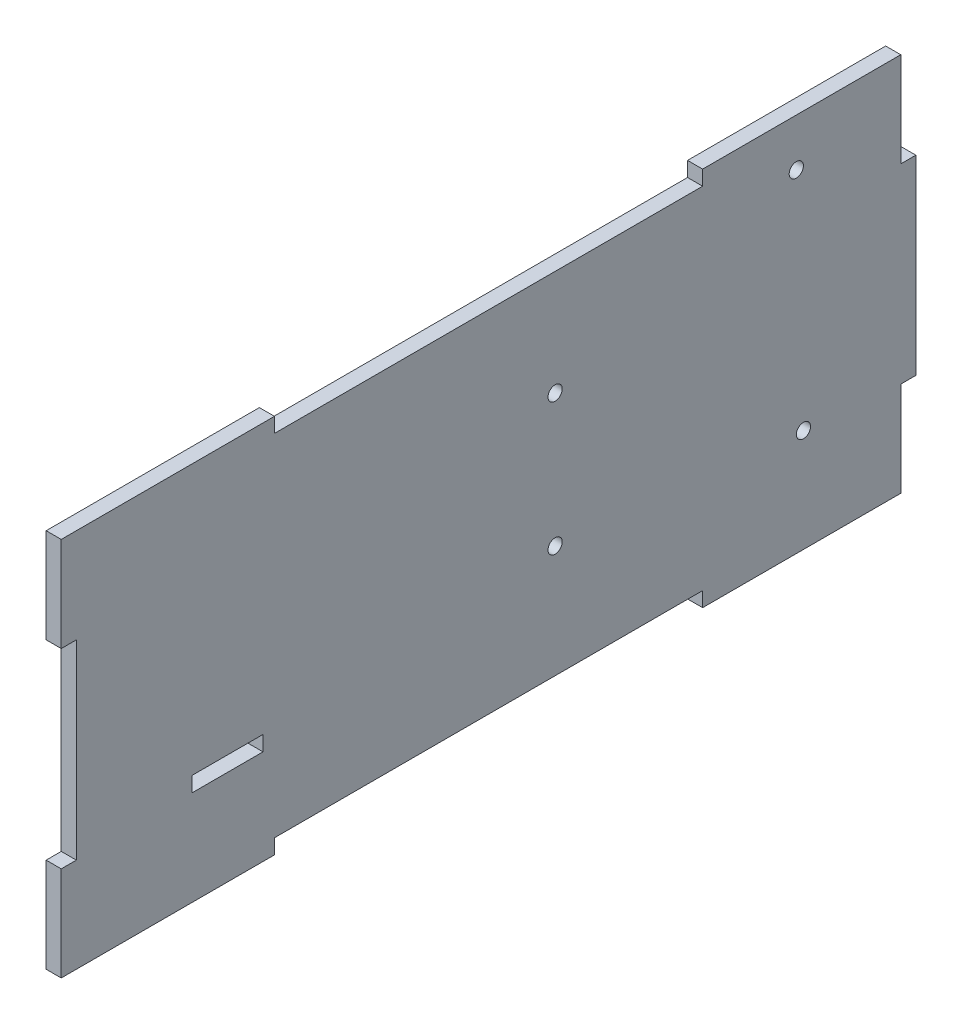
from build123d import *

# Parameters (mm, degrees)
SKETCH2_W           = 180
SKETCH2_H           = 80
BOSS_EXTRUDE1_DEPTH = 3.18
SKETCH3_W           = 3.18
SKETCH3_H           = 40.18
CUT_EXTRUDE1_DEPTH  = 3.18
SKETCH4_W           = 90.18
SKETCH4_H           = 3.12
CUT_EXTRUDE2_DEPTH  = 3.18
SKETCH5_W           = 3.18
SKETCH5_H           = 19.91
CUT_EXTRUDE3_DEPTH  = 3.18
SKETCH7_R           = 1.5
CUT_EXTRUDE4_DEPTH  = 3.18
SKETCH9_W           = 15
SKETCH9_H           = 3.18
CUT_EXTRUDE6_DEPTH  = 4.18


with BuildPart() as part:
    # Sketch2 → Boss-Extrude1 (new body)
    with BuildSketch(Plane(origin=(0, 0, 0), x_dir=(0, 0, -1), z_dir=(1, 0, 0))):
        Rectangle(SKETCH2_W, SKETCH2_H)
    extrude(amount=BOSS_EXTRUDE1_DEPTH)

    # Sketch3 → Cut-Extrude1 (cut)
    with BuildSketch(Plane(origin=(3.18, 0, 0), x_dir=(0, 0, -1), z_dir=(1, 0, 0))):
        with Locations((-88.41, 0)):
            Rectangle(SKETCH3_W, SKETCH3_H)
    extrude(amount=-CUT_EXTRUDE1_DEPTH, mode=Mode.SUBTRACT)

    # Sketch4 → Cut-Extrude2 (cut)
    with BuildSketch(Plane(origin=(3.18, 0, 0), x_dir=(0, 0, -1), z_dir=(1, 0, 0))):
        with Locations((0, 38.44)):
            Rectangle(SKETCH4_W, SKETCH4_H)
    cut_extrude2 = extrude(amount=-CUT_EXTRUDE2_DEPTH, mode=Mode.SUBTRACT)

    # Mirror1: Cut-Extrude2 across plane
    add(cut_extrude2.mirror(Plane.ZX), mode=Mode.SUBTRACT)

    # Sketch5 → Cut-Extrude3 (cut)
    with BuildSketch(Plane(origin=(3.18, 0, 0), x_dir=(0, 0, -1), z_dir=(1, 0, 0))):
        with Locations((88.41, 30.045)):
            Rectangle(SKETCH5_W, SKETCH5_H)
    cut_extrude3 = extrude(amount=-CUT_EXTRUDE3_DEPTH, mode=Mode.SUBTRACT)

    # Mirror2: Cut-Extrude3 across plane
    add(cut_extrude3.mirror(Plane.ZX), mode=Mode.SUBTRACT)

    # Sketch7 → Cut-Extrude4 (cut)
    with BuildSketch(Plane(origin=(3.18, 0, 0), x_dir=(0, 0, -1), z_dir=(1, 0, 0))):
        with Locations((64.82, 30)):
            Circle(SKETCH7_R)
        with Locations((14.02, 14.7)):
            Circle(SKETCH7_R)
        with Locations((14.02, -13.2)):
            Circle(SKETCH7_R)
        with Locations((66.32, -18.3)):
            Circle(SKETCH7_R)
    extrude(amount=-CUT_EXTRUDE4_DEPTH, mode=Mode.SUBTRACT)

    # Sketch9 → Cut-Extrude6 (cut, through all)
    with BuildSketch(Plane.ZY):
        with Locations((55, -18.41)):
            Rectangle(SKETCH9_W, SKETCH9_H)
    extrude(amount=-CUT_EXTRUDE6_DEPTH, mode=Mode.SUBTRACT)


solid = part.part
